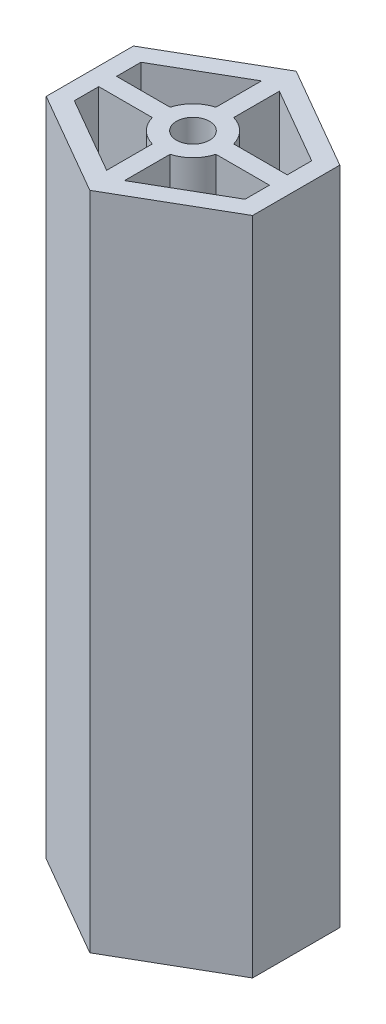
from build123d import *

# Parameters (mm, degrees)
SKETCH1_R           = 2
BOSS_EXTRUDE2_DEPTH = 80


with BuildPart() as part:
    # Sketch1 → Boss-Extrude2 (new body)
    with BuildSketch(Plane(origin=(0, 0, 0), x_dir=(1, 0, 0), z_dir=(0, 1, 0))):
        Polygon((-12.5, 5.283121635), (-12.5, -5.283121635), (0, -12.5), (12.5, -5.283121635), (12.5, 5.283121635), (0, 12.5), align=None)
        Circle(SKETCH1_R, mode=Mode.SUBTRACT)
        with BuildLine():
            Line((-1.08, 9.382308546), (-1.08, 3.851441289))
            ThreePointArc((-1.08, 3.851441289), (-2.828427125, 2.828427125), (-3.851441289, 1.08))
            Line((-3.851441289, 1.08), (-10.34, 1.08))
            Line((-10.34, 1.08), (-10.34, 4.036045054))
            Line((-10.34, 4.036045054), (-1.08, 9.382308546))
        make_face(mode=Mode.SUBTRACT)
        with BuildLine():
            Line((1.08, 9.382308546), (1.08, 3.851441289))
            ThreePointArc((1.08, 3.851441289), (2.828427125, 2.828427125), (3.851441289, 1.08))
            Line((3.851441289, 1.08), (10.34, 1.08))
            Line((10.34, 1.08), (10.34, 4.036045054))
            Line((10.34, 4.036045054), (1.08, 9.382308546))
        make_face(mode=Mode.SUBTRACT)
        with BuildLine():
            Line((-10.34, -1.08), (-3.851441289, -1.08))
            ThreePointArc((-3.851441289, -1.08), (-2.828427125, -2.828427125), (-1.08, -3.851441289))
            Line((-1.08, -3.851441289), (-1.08, -9.382308546))
            Line((-1.08, -9.382308546), (-10.34, -4.036045054))
            Line((-10.34, -4.036045054), (-10.34, -1.08))
        make_face(mode=Mode.SUBTRACT)
        with BuildLine():
            Line((1.08, -3.851441289), (1.08, -9.382308546))
            Line((1.08, -9.382308546), (10.34, -4.036045054))
            Line((10.34, -4.036045054), (10.34, -1.08))
            Line((10.34, -1.08), (3.851441289, -1.08))
            ThreePointArc((3.851441289, -1.08), (2.828427125, -2.828427125), (1.08, -3.851441289))
        make_face(mode=Mode.SUBTRACT)
    extrude(amount=BOSS_EXTRUDE2_DEPTH)


solid = part.part
